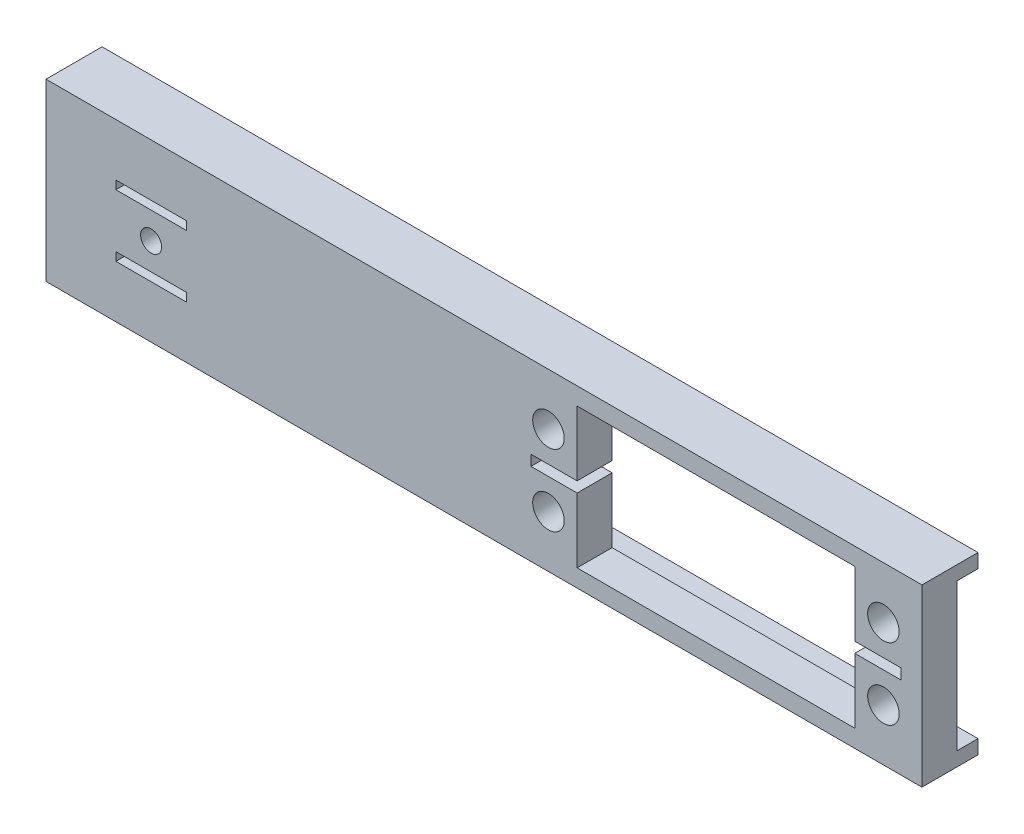
from build123d import *

# Parameters (mm, degrees)
SKETCH1_W           = 125
SKETCH1_H           = 25
SKETCH1_W_2         = 10.0584
SKETCH1_H_2         = 10.0584
SKETCH1_W_3         = 52.8
SKETCH1_H_3         = 20
SKETCH1_H_4         = 7.6454
SKETCH1_R           = 1.5
SKETCH1_W_4         = 6.588
SKETCH1_H_5         = 9.25
SKETCH1_R_2         = 2.25
BOSS_EXTRUDE1_DEPTH = 5
SKETCH3_W           = 125
SKETCH3_H           = 8
BOSS_EXTRUDE2_DEPTH = 2
BOSS_EXTRUDE3_START = -25
SKETCH3_2_W         = 125
SKETCH3_2_H         = 8
BOSS_EXTRUDE3_DEPTH = 2


with BuildPart() as part:
    # Sketch1 → Boss-Extrude1 (new body)
    with BuildSketch(Plane.XY):
        Rectangle(SKETCH1_W, SKETCH1_H)
        with Locations((-47.5, 0)):
            Rectangle(SKETCH1_W_2, SKETCH1_H_2, mode=Mode.SUBTRACT)
        with Locations((33.1, 0)):
            Rectangle(SKETCH1_W_3, SKETCH1_H_3, mode=Mode.SUBTRACT)
        with Locations((-47.5, 0)):
            Rectangle(SKETCH1_W_2, SKETCH1_H_4)
        with Locations((-47.5, 0)):
            Circle(SKETCH1_R, mode=Mode.SUBTRACT)
        with Locations((56.206, 5.375)):
            Rectangle(SKETCH1_W_4, SKETCH1_H_5)
        with Locations((57, 5.1)):
            Circle(SKETCH1_R_2, mode=Mode.SUBTRACT)
        with Locations((56.206, -5.375)):
            Rectangle(SKETCH1_W_4, SKETCH1_H_5)
        with Locations((57, -5.1)):
            Circle(SKETCH1_R_2, mode=Mode.SUBTRACT)
        with Locations((9.994, -5.375)):
            Rectangle(SKETCH1_W_4, SKETCH1_H_5)
        with Locations((9.2, -5.1)):
            Circle(SKETCH1_R_2, mode=Mode.SUBTRACT)
        with Locations((9.994, 5.375)):
            Rectangle(SKETCH1_W_4, SKETCH1_H_5)
        with Locations((9.2, 5.1)):
            Circle(SKETCH1_R_2, mode=Mode.SUBTRACT)
    extrude(amount=BOSS_EXTRUDE1_DEPTH)

    # Sketch3 → Boss-Extrude2 (add)
    with BuildSketch(Plane(origin=(0, 12.5, 0), x_dir=(1, 0, 0), z_dir=(0, 1, 0))):
        with Locations((0, -1)):
            Rectangle(SKETCH3_W, SKETCH3_H)
    extrude(amount=-BOSS_EXTRUDE2_DEPTH)

    # Sketch3_2 → Boss-Extrude3 (add)
    with BuildSketch(Plane(origin=(0, 12.5, 0), x_dir=(1, 0, 0), z_dir=(0, 1, 0)).offset(BOSS_EXTRUDE3_START)):
        with Locations((0, -1)):
            Rectangle(SKETCH3_2_W, SKETCH3_2_H)
    extrude(amount=BOSS_EXTRUDE3_DEPTH)


solid = part.part
